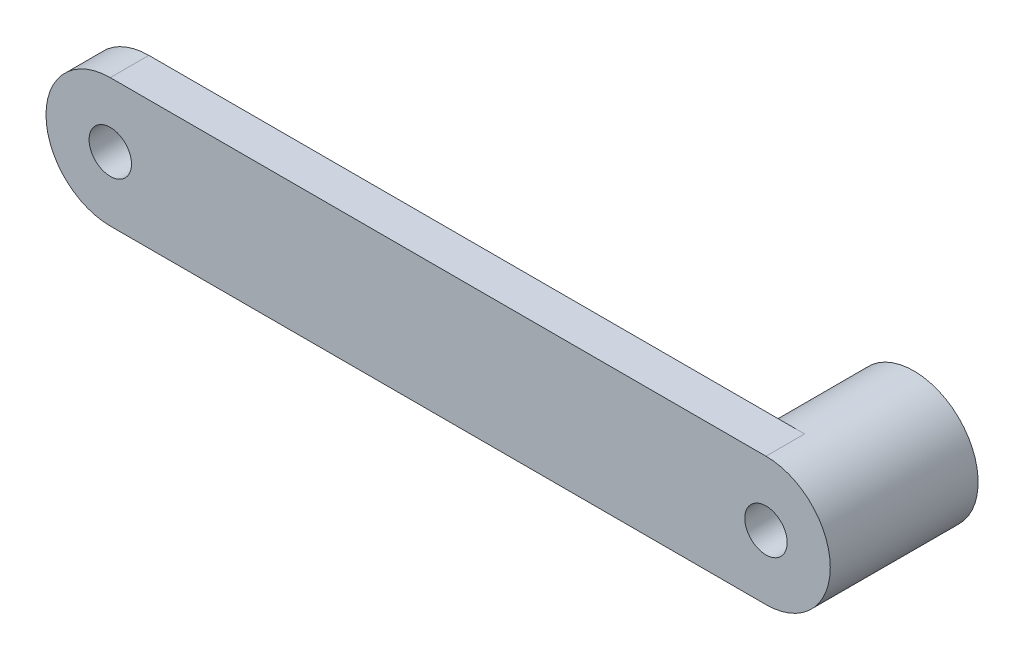
from build123d import *

# Parameters (mm, degrees)
SKETCH_1_R      = 1.65
EXTRUDE_1_DEPTH = 3
SKETCH_2_R      = 5
SKETCH_2_R_2    = 1.65
EXTRUDE_2_DEPTH = 8.5


with BuildPart() as part:
    # 草圖1 → 填料-伸長1 (new body)
    with BuildSketch(Plane.XY):
        with BuildLine():
            Line((0, 5), (51, 5))
            ThreePointArc((51, 5), (56, 0), (51, -5))
            Line((51, -5), (0, -5))
            ThreePointArc((0, -5), (-5, 0), (0, 5))
        make_face()
        Circle(SKETCH_1_R, mode=Mode.SUBTRACT)
        with Locations((51, 0)):
            Circle(SKETCH_1_R, mode=Mode.SUBTRACT)
    extrude(amount=EXTRUDE_1_DEPTH)

    # 草圖2 → 填料-伸長2 (add)
    with BuildSketch(Plane(origin=(0, 0, 0), x_dir=(-1, 0, 0), z_dir=(0, 0, -1))):
        with Locations((-51, 0)):
            Circle(SKETCH_2_R)
        with Locations((-51, 0)):
            Circle(SKETCH_2_R_2, mode=Mode.SUBTRACT)
    extrude(amount=EXTRUDE_2_DEPTH)


solid = part.part
